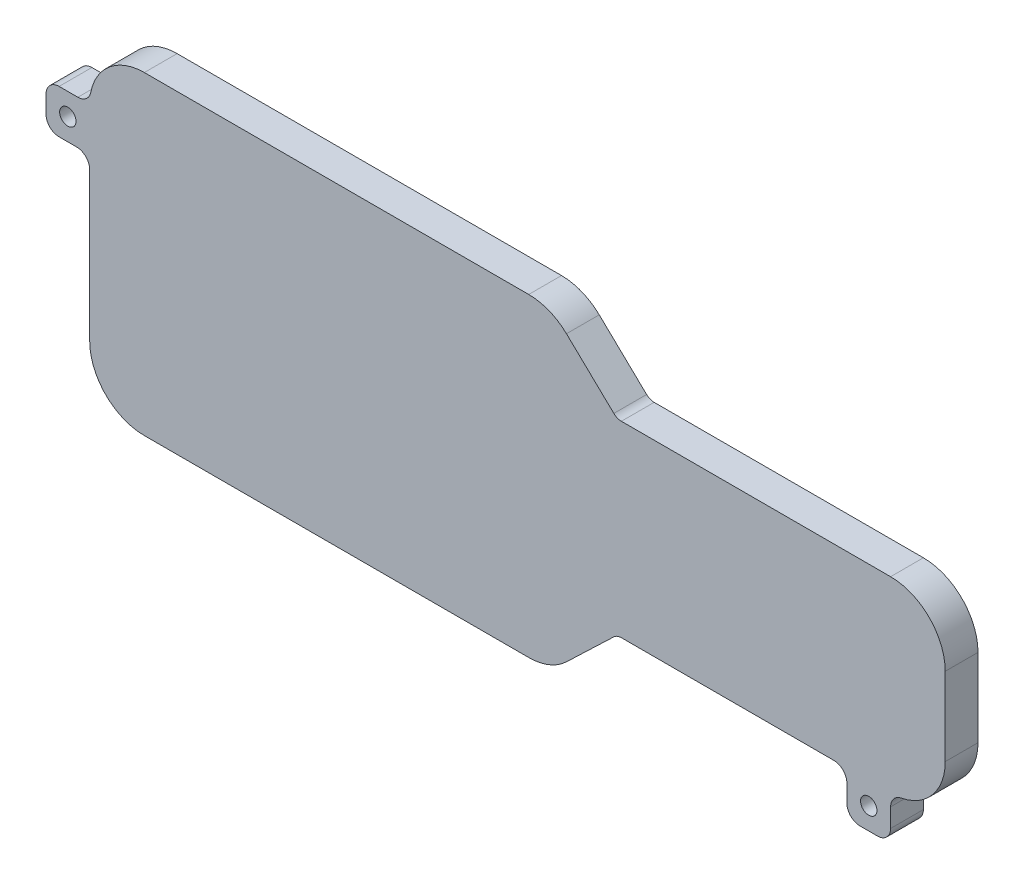
from build123d import *

# Parameters (mm, degrees)
BOSS_EXTRUDE2_DEPTH      = 12
BOSS_EXTRUDE2_DEPTH_BACK = 3
BOSS_EXTRUDE3_DEPTH      = 3
SKETCH8_W                = 4
SKETCH8_H                = 4
BOSS_EXTRUDE4_DEPTH      = 15
FILLET2_R                = 1.2
SKETCH9_R                = 0.75
CUT_EXTRUDE3_DEPTH       = 16
SKETCH10_R               = 3.5
CUT_EXTRUDE4_DEPTH       = 1.5
FILLET3_R                = 0.3
CUT_EXTRUDE5_DEPTH       = 12


with BuildPart() as part:
    # Sketch3 → Boss-Extrude2 (new body, two sides)
    with BuildSketch(Plane.XY) as boss_extrude2_sk:
        with BuildLine():
            Line((-69.81, 19.47), (-34.625063383, 19.47))
            ThreePointArc((-34.625063383, 19.47), (-32.763487521, 19.110531791), (-31.169582594, 18.083814123))
            Line((-31.169582594, 18.083814123), (-26.833005647, 13.937237175))
            ThreePointArc((-26.833005647, 13.937237175), (-26.514224661, 13.731893642), (-26.141909489, 13.66))
            Line((-26.141909489, 13.66), (-1.5, 13.66))
            ThreePointArc((-1.5, 13.66), (2.035533906, 12.195533906), (3.5, 8.66))
            Line((3.5, 8.66), (3.5, 1.5))
            ThreePointArc((3.5, 1.5), (2.035533906, -2.035533906), (-1.5, -3.5))
            Line((-1.5, -3.5), (-26.141909489, -3.5))
            ThreePointArc((-26.141909489, -3.5), (-26.514224661, -3.571893642), (-26.833005647, -3.777237175))
            Line((-26.833005647, -3.777237175), (-31.169582594, -7.923814123))
            ThreePointArc((-31.169582594, -7.923814123), (-32.763487521, -8.950531791), (-34.625063383, -9.31))
            Line((-34.625063383, -9.31), (-69.81, -9.31))
            ThreePointArc((-69.81, -9.31), (-73.345533906, -7.845533906), (-74.81, -4.31))
            Line((-74.81, -4.31), (-74.81, 14.47))
            ThreePointArc((-74.81, 14.47), (-73.345533906, 18.005533906), (-69.81, 19.47))
        make_face()
        with BuildLine():
            Line((-69.81, 17.47), (-34.625063383, 17.47))
            ThreePointArc((-34.625063383, 17.47), (-33.508117866, 17.254319075), (-32.55177491, 16.638288474))
            Line((-32.55177491, 16.638288474), (-28.215197962, 12.491711526))
            ThreePointArc((-28.215197962, 12.491711526), (-27.258855006, 11.875680925), (-26.141909489, 11.66))
            Line((-26.141909489, 11.66), (-1.5, 11.66))
            ThreePointArc((-1.5, 11.66), (0.621320344, 10.781320344), (1.5, 8.66))
            Line((1.5, 8.66), (1.5, 1.5))
            ThreePointArc((1.5, 1.5), (0.621320344, -0.621320344), (-1.5, -1.5))
            Line((-1.5, -1.5), (-26.141909489, -1.5))
            ThreePointArc((-26.141909489, -1.5), (-27.258855006, -1.715680925), (-28.215197962, -2.331711526))
            Line((-28.215197962, -2.331711526), (-32.55177491, -6.478288474))
            ThreePointArc((-32.55177491, -6.478288474), (-33.508117866, -7.094319075), (-34.625063383, -7.31))
            Line((-34.625063383, -7.31), (-69.81, -7.31))
            ThreePointArc((-69.81, -7.31), (-71.931320344, -6.431320344), (-72.81, -4.31))
            Line((-72.81, -4.31), (-72.81, 14.47))
            ThreePointArc((-72.81, 14.47), (-71.931320344, 16.591320344), (-69.81, 17.47))
        make_face(mode=Mode.SUBTRACT)
    extrude(amount=BOSS_EXTRUDE2_DEPTH)
    extrude(boss_extrude2_sk.sketch, amount=-BOSS_EXTRUDE2_DEPTH_BACK)

    # Sketch5 → Boss-Extrude3 (add)
    with BuildSketch(Plane(origin=(0, 0, -3), x_dir=(-1, 0, 0), z_dir=(0, 0, -1))):
        with BuildLine():
            Line((72.81, 14.47), (72.81, -4.31))
            ThreePointArc((72.81, -4.31), (71.931320344, -6.431320344), (69.81, -7.31))
            Line((69.81, -7.31), (34.625063383, -7.31))
            ThreePointArc((34.625063383, -7.31), (33.508117866, -7.094319075), (32.55177491, -6.478288474))
            Line((32.55177491, -6.478288474), (28.215197962, -2.331711526))
            ThreePointArc((28.215197962, -2.331711526), (27.258855006, -1.715680925), (26.141909489, -1.5))
            Line((26.141909489, -1.5), (1.5, -1.5))
            ThreePointArc((1.5, -1.5), (-0.621320344, -0.621320344), (-1.5, 1.5))
            Line((-1.5, 1.5), (-1.5, 8.66))
            ThreePointArc((-1.5, 8.66), (-0.621320344, 10.781320344), (1.5, 11.66))
            Line((1.5, 11.66), (26.141909489, 11.66))
            ThreePointArc((26.141909489, 11.66), (27.258855006, 11.875680925), (28.215197962, 12.491711526))
            Line((28.215197962, 12.491711526), (32.55177491, 16.638288474))
            ThreePointArc((32.55177491, 16.638288474), (33.508117866, 17.254319075), (34.625063383, 17.47))
            Line((34.625063383, 17.47), (69.81, 17.47))
            ThreePointArc((69.81, 17.47), (71.931320344, 16.591320344), (72.81, 14.47))
        make_face()
    extrude(amount=-BOSS_EXTRUDE3_DEPTH)

    # Sketch8 → Boss-Extrude4 (add, through all)
    with BuildSketch(Plane.XY.offset(12)):
        with Locations((-76.81, 12.47)):
            Rectangle(SKETCH8_W, SKETCH8_H)
        with Locations((-3.5, -5.5)):
            Rectangle(SKETCH8_W, SKETCH8_H)
    extrude(amount=-BOSS_EXTRUDE4_DEPTH)

    # Fillet2
    fillet2_edges = [part.edges().sort_by_distance(p)[0] for p in [
        (-74.81, 10.47, 4.5),
        (-78.81, 10.47, 4.5),
        (-78.81, 14.47, 4.5),
        (-1.5, -7.5, 4.5),
        (-5.5, -7.5, 4.5),
        (-5.5, -3.5, 4.5),
        (-1.5, -3.5, 4.5),
        (-74.81, 14.47, 4.5),
    ]]
    fillet(fillet2_edges, radius=FILLET2_R)

    # Sketch9 → Cut-Extrude3 (cut, through all)
    with BuildSketch(Plane.XY.offset(12)):
        with Locations((-76.81, 12.47)):
            Circle(SKETCH9_R)
        with Locations((-3.5, -5.5)):
            Circle(SKETCH9_R)
    extrude(amount=-CUT_EXTRUDE3_DEPTH, mode=Mode.SUBTRACT)

    # Sketch10 → Cut-Extrude4 (cut)
    with BuildSketch(Plane(origin=(0, 0, -3), x_dir=(-1, 0, 0), z_dir=(0, 0, -1))):
        with Locations((62.81, 5.08)):
            Circle(SKETCH10_R)
    extrude(amount=-CUT_EXTRUDE4_DEPTH, mode=Mode.SUBTRACT)

    # Fillet3
    fillet3_edges = [part.edges().sort_by_distance(p)[0] for p in [
        (-59.31, 5.08, -3),
    ]]
    fillet(fillet3_edges, radius=FILLET3_R)

    # Sketch11 → Cut-Extrude5 (cut)
    with BuildSketch(Plane.XY.offset(12)):
        with BuildLine():
            Line((-4.3, -7.5), (-2.7, -7.5))
            ThreePointArc((-2.7, -7.5), (-1.851471863, -7.148528137), (-1.5, -6.3))
            Line((-1.5, -6.3), (-1.5, -4.58276253))
            ThreePointArc((-1.5, -4.58276253), (-1.227013937, -3.820761768), (-0.532258065, -3.405453653))
            ThreePointArc((-0.532258065, -3.405453653), (2.362558069, -1.675003175), (3.5, 1.5))
            Line((3.5, 1.5), (3.5, 8.66))
            ThreePointArc((3.5, 8.66), (2.035533906, 12.195533906), (-1.5, 13.66))
            Line((-1.5, 13.66), (-26.141909489, 13.66))
            ThreePointArc((-26.141909489, 13.66), (-26.514224661, 13.731893642), (-26.833005647, 13.937237175))
            Line((-26.833005647, 13.937237175), (-31.169582594, 18.083814123))
            ThreePointArc((-31.169582594, 18.083814123), (-32.763487521, 19.110531791), (-34.625063383, 19.47))
            Line((-34.625063383, 19.47), (-69.81, 19.47))
            ThreePointArc((-69.81, 19.47), (-72.985003175, 18.332558069), (-74.715453653, 15.437741935))
            ThreePointArc((-74.715453653, 15.437741935), (-75.130761768, 14.742986063), (-75.89276253, 14.47))
            Line((-75.89276253, 14.47), (-77.61, 14.47))
            ThreePointArc((-77.61, 14.47), (-78.458528137, 14.118528137), (-78.81, 13.27))
            Line((-78.81, 13.27), (-78.81, 11.67))
            ThreePointArc((-78.81, 11.67), (-78.458528137, 10.821471863), (-77.61, 10.47))
            Line((-77.61, 10.47), (-76.01, 10.47))
            ThreePointArc((-76.01, 10.47), (-75.161471863, 10.118528137), (-74.81, 9.27))
            Line((-74.81, 9.27), (-74.81, -4.31))
            ThreePointArc((-74.81, -4.31), (-73.345533906, -7.845533906), (-69.81, -9.31))
            Line((-69.81, -9.31), (-34.625063383, -9.31))
            ThreePointArc((-34.625063383, -9.31), (-32.763487521, -8.950531791), (-31.169582594, -7.923814123))
            Line((-31.169582594, -7.923814123), (-26.833005647, -3.777237175))
            ThreePointArc((-26.833005647, -3.777237175), (-26.514224661, -3.571893642), (-26.141909489, -3.5))
            Line((-26.141909489, -3.5), (-6.7, -3.5))
            ThreePointArc((-6.7, -3.5), (-5.851471863, -3.851471863), (-5.5, -4.7))
            Line((-5.5, -4.7), (-5.5, -6.3))
            ThreePointArc((-5.5, -6.3), (-5.148528137, -7.148528137), (-4.3, -7.5))
        make_face()
        with BuildLine():
            Line((-69.81, -7.31), (-34.625063383, -7.31))
            ThreePointArc((-34.625063383, -7.31), (-33.508117866, -7.094319075), (-32.55177491, -6.478288474))
            Line((-32.55177491, -6.478288474), (-28.215197962, -2.331711526))
            ThreePointArc((-28.215197962, -2.331711526), (-27.258855006, -1.715680925), (-26.141909489, -1.5))
            Line((-26.141909489, -1.5), (-1.5, -1.5))
            ThreePointArc((-1.5, -1.5), (0.621320344, -0.621320344), (1.5, 1.5))
            Line((1.5, 1.5), (1.5, 8.66))
            ThreePointArc((1.5, 8.66), (0.621320344, 10.781320344), (-1.5, 11.66))
            Line((-1.5, 11.66), (-26.141909489, 11.66))
            ThreePointArc((-26.141909489, 11.66), (-27.258855006, 11.875680925), (-28.215197962, 12.491711526))
            Line((-28.215197962, 12.491711526), (-32.55177491, 16.638288474))
            ThreePointArc((-32.55177491, 16.638288474), (-33.508117866, 17.254319075), (-34.625063383, 17.47))
            Line((-34.625063383, 17.47), (-69.81, 17.47))
            ThreePointArc((-69.81, 17.47), (-71.931320344, 16.591320344), (-72.81, 14.47))
            Line((-72.81, 14.47), (-72.81, -4.31))
            ThreePointArc((-72.81, -4.31), (-71.931320344, -6.431320344), (-69.81, -7.31))
        make_face(mode=Mode.SUBTRACT)
    extrude(amount=-CUT_EXTRUDE5_DEPTH, mode=Mode.SUBTRACT)


solid = part.part
